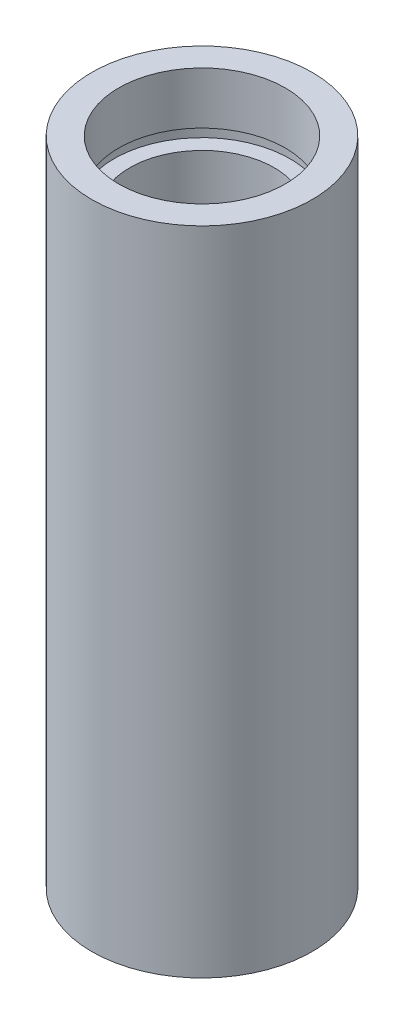
from build123d import *


with BuildPart() as part:
    # 草图1 → 旋转1 (revolve)
    with BuildSketch(Plane.XY, mode=Mode.PRIVATE) as revolve_1_sk:
        Polygon((7, 0), (7, 4.5), (7.6, 4.5), (7.6, 5.5), (6.25, 5.5), (6.25, 50.8), (7.6, 50.8), (7.6, 51.8), (7.2, 51.8), (7.2, 56.3), (9.525, 56.3), (9.525, 0), align=None)
    revolve(revolve_1_sk.sketch.rotate(Axis((0, 161.376166943, 0), (0, -1, 0)), 90), axis=Axis((0, 161.376166943, 0), (0, -1, 0)))  # turned: the seam where the file's is


solid = part.part
